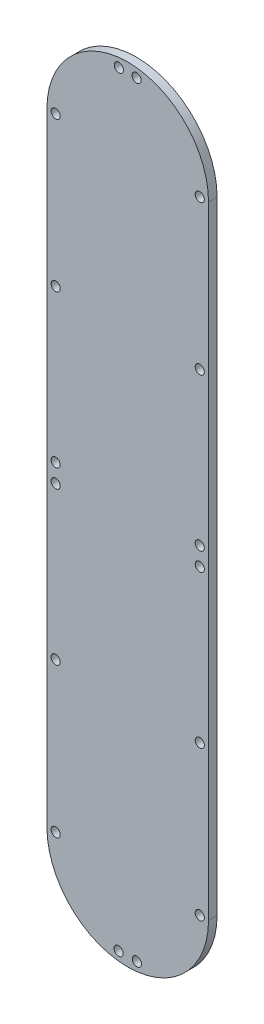
from build123d import *

# Parameters (mm, degrees)
SKETCH1_R           = 1.7
BOSS_EXTRUDE1_DEPTH = 3.175


with BuildPart() as part:
    # Sketch1 → Boss-Extrude1 (new body)
    with BuildSketch(Plane(origin=(0, 0, 0), x_dir=(-1, 0, 0), z_dir=(0, 0, -1))):
        with BuildLine():
            Line((5.417282063, -59.58290593), (5.417282063, 171.394622999))
            ThreePointArc((5.417282063, 171.394622999), (-24.582717937, 201.394622999), (-54.582717937, 171.394622999))
            Line((-54.582717937, 171.394622999), (-54.582717937, -59.58290593))
            ThreePointArc((-54.582717937, -59.58290593), (-24.582717937, -89.58290593), (5.417282063, -59.58290593))
        make_face()
        with Locations((2.167282063, 52.505858535)):
            Circle(SKETCH1_R, mode=Mode.SUBTRACT)
        with Locations((-51.332717937, 59.305858535)):
            Circle(SKETCH1_R, mode=Mode.SUBTRACT)
        with Locations((-51.332717937, 52.505858535)):
            Circle(SKETCH1_R, mode=Mode.SUBTRACT)
        with Locations((-21.282717937, 197.940291196)):
            Circle(SKETCH1_R, mode=Mode.SUBTRACT)
        with Locations((2.167282063, -4.094141465)):
            Circle(SKETCH1_R, mode=Mode.SUBTRACT)
        with Locations((-51.332717937, -4.094141465)):
            Circle(SKETCH1_R, mode=Mode.SUBTRACT)
        with Locations((-51.332717937, -59.58290593)):
            Circle(SKETCH1_R, mode=Mode.SUBTRACT)
        with Locations((2.167282063, 115.905858535)):
            Circle(SKETCH1_R, mode=Mode.SUBTRACT)
        with Locations((-51.332717937, 115.905858535)):
            Circle(SKETCH1_R, mode=Mode.SUBTRACT)
        with Locations((2.167282063, 171.394622999)):
            Circle(SKETCH1_R, mode=Mode.SUBTRACT)
        with Locations((-27.982717937, -86.115951364)):
            Circle(SKETCH1_R, mode=Mode.SUBTRACT)
        with Locations((2.167282063, 59.305858535)):
            Circle(SKETCH1_R, mode=Mode.SUBTRACT)
        with Locations((-51.332717937, 171.394622999)):
            Circle(SKETCH1_R, mode=Mode.SUBTRACT)
        with Locations((-21.182717937, -86.115951364)):
            Circle(SKETCH1_R, mode=Mode.SUBTRACT)
        with Locations((2.167282063, -59.58290593)):
            Circle(SKETCH1_R, mode=Mode.SUBTRACT)
        with Locations((-27.882717937, 197.940291196)):
            Circle(SKETCH1_R, mode=Mode.SUBTRACT)
    extrude(amount=-BOSS_EXTRUDE1_DEPTH)


solid = part.part
